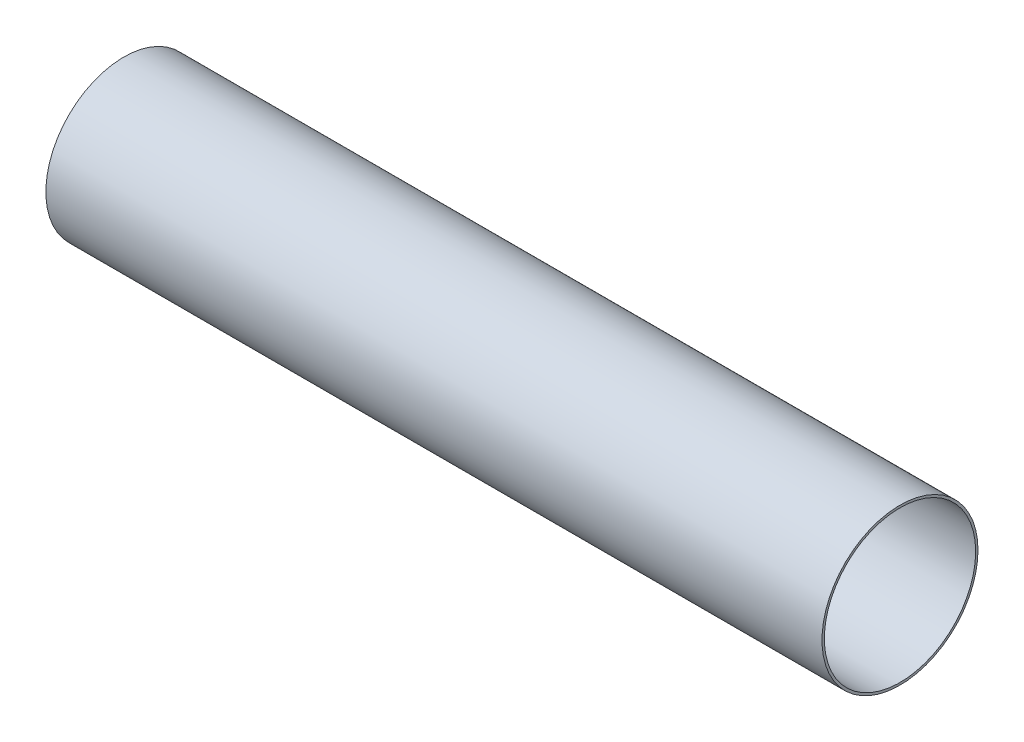
from build123d import *

# Parameters (mm, degrees)
SKETCH1_R           = 51.054
SKETCH1_R_2         = 49.53
BOSS_EXTRUDE1_DEPTH = 508


with BuildPart() as part:
    # Sketch1 → Boss-Extrude1 (new body)
    with BuildSketch(Plane.YZ):
        Circle(SKETCH1_R)
        Circle(SKETCH1_R_2, mode=Mode.SUBTRACT)
    extrude(amount=BOSS_EXTRUDE1_DEPTH)


solid = part.part
